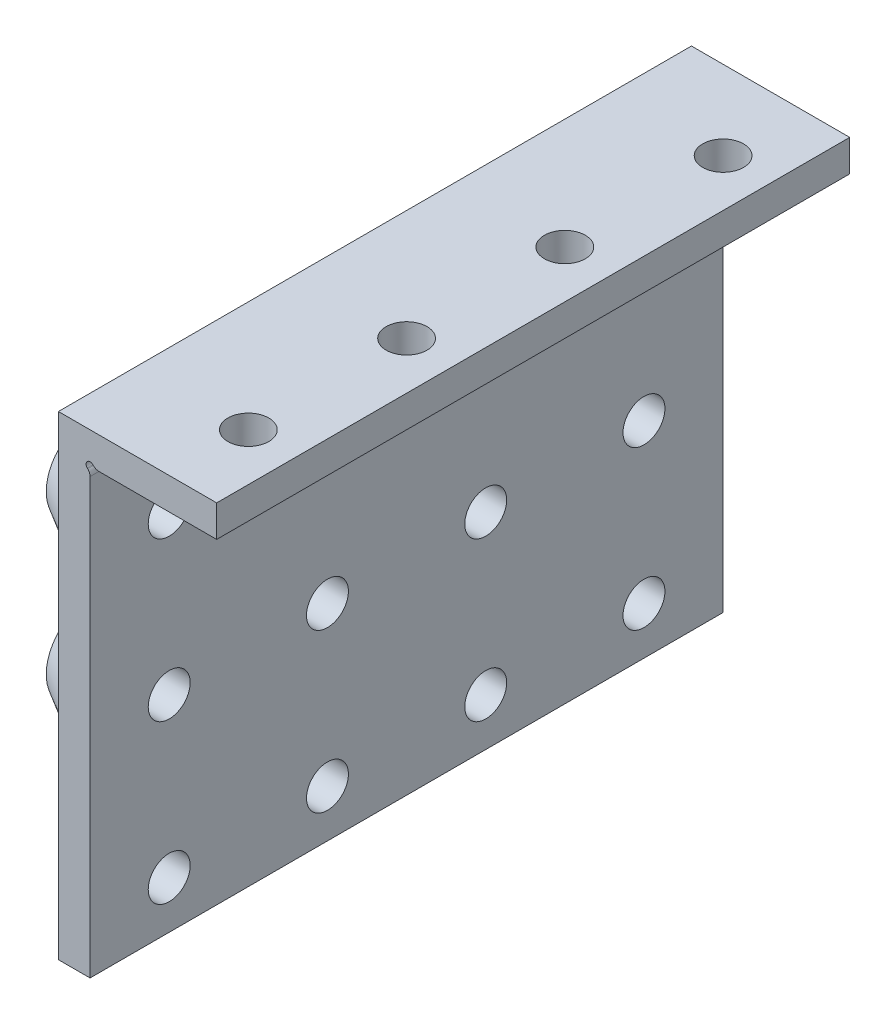
from build123d import *

# Parameters (mm, degrees)
BOSS_EXTRUDE1_DEPTH            = 80
SKETCH2_R                      = 9
BOSS_EXTRUDE2_DEPTH            = 6
BOSS_EXTRUDE2_DRAFT            = -30
BOSS_EXTRUDE2_PROFILE_2_DEPTH  = 6
BOSS_EXTRUDE2_PROFILE_2_DRAFT  = -30
BOSS_EXTRUDE2_PROFILE_3_DEPTH  = 6
BOSS_EXTRUDE2_PROFILE_3_DRAFT  = -30
BOSS_EXTRUDE2_PROFILE_4_DEPTH  = 6
BOSS_EXTRUDE2_PROFILE_4_DRAFT  = -30
BOSS_EXTRUDE2_PROFILE_5_DEPTH  = 6
BOSS_EXTRUDE2_PROFILE_5_DRAFT  = -30
BOSS_EXTRUDE2_PROFILE_6_DEPTH  = 6
BOSS_EXTRUDE2_PROFILE_6_DRAFT  = -30
BOSS_EXTRUDE2_PROFILE_7_DEPTH  = 6
BOSS_EXTRUDE2_PROFILE_7_DRAFT  = -30
BOSS_EXTRUDE2_PROFILE_8_DEPTH  = 6
BOSS_EXTRUDE2_PROFILE_8_DRAFT  = -30
CUT_EXTRUDE1_REACH             = 103.98
SKETCH2_4_R                    = 2.65
CUT_EXTRUDE1_DIRECTION_2_REACH = 103.98
CUT_EXTRUDE2_REACH             = 103.054
SKETCH3_R                      = 2.584003328
CUT_EXTRUDE3_REACH             = 105.325


with BuildPart() as part:
    # Sketch1 → Boss-Extrude1 (new body)
    with BuildSketch(Plane.XY):
        Polygon((0, 0), (-20, 0), (-20, -60), (-16, -60), (-16, -4), (0, -4), align=None)
    extrude(amount=BOSS_EXTRUDE1_DEPTH)


with BuildPart() as boss_extrude2_tool:
    # Sketch2 → Boss-Extrude2 (with draft: the straight prism first)
    with BuildSketch(Plane(origin=(-20, 0, 0), x_dir=(0, 0, -1), z_dir=(1, 0, 0))):
        with Locations((-10, -14)):
            Circle(SKETCH2_R)
    extrude(amount=-BOSS_EXTRUDE2_DEPTH)
    # Boss-Extrude2: the draft: its side faces are tilted about the plane it starts from
    boss_extrude2_sides = [boss_extrude2_tool.faces().sort_by_distance(p)[0] for p in [
        (-23, -14, 19),
    ]]
    draft(boss_extrude2_sides, Plane(origin=(-20, 0, 0), x_dir=(0, 0, -1), z_dir=(1, 0, 0)), BOSS_EXTRUDE2_DRAFT)


with BuildPart() as part_1:
    add(part.part)

    # Boss-Extrude2: add boss_extrude2_tool
    add(boss_extrude2_tool.part)


with BuildPart() as boss_extrude2_profile_2_tool:
    # Sketch2 → Boss-Extrude2 profile 2 (with draft: the straight prism first)
    with BuildSketch(Plane(origin=(-20, 0, 0), x_dir=(0, 0, -1), z_dir=(1, 0, 0))):
        with Locations((-30, -14)):
            Circle(SKETCH2_R)
    extrude(amount=-BOSS_EXTRUDE2_PROFILE_2_DEPTH)
    # Boss-Extrude2 profile 2: the draft: its side faces are tilted about the plane it starts from
    boss_extrude2_profile_2_sides = [boss_extrude2_profile_2_tool.faces().sort_by_distance(p)[0] for p in [
        (-23, -14, 39),
    ]]
    draft(boss_extrude2_profile_2_sides, Plane(origin=(-20, 0, 0), x_dir=(0, 0, -1), z_dir=(1, 0, 0)), BOSS_EXTRUDE2_PROFILE_2_DRAFT)


with BuildPart() as part_2:
    add(part_1.part)

    # Boss-Extrude2 profile 2: add boss_extrude2_profile_2_tool
    add(boss_extrude2_profile_2_tool.part)


with BuildPart() as boss_extrude2_profile_3_tool:
    # Sketch2 → Boss-Extrude2 profile 3 (with draft: the straight prism first)
    with BuildSketch(Plane(origin=(-20, 0, 0), x_dir=(0, 0, -1), z_dir=(1, 0, 0))):
        with Locations((-50, -14)):
            Circle(SKETCH2_R)
    extrude(amount=-BOSS_EXTRUDE2_PROFILE_3_DEPTH)
    # Boss-Extrude2 profile 3: the draft: its side faces are tilted about the plane it starts from
    boss_extrude2_profile_3_sides = [boss_extrude2_profile_3_tool.faces().sort_by_distance(p)[0] for p in [
        (-23, -14, 59),
    ]]
    draft(boss_extrude2_profile_3_sides, Plane(origin=(-20, 0, 0), x_dir=(0, 0, -1), z_dir=(1, 0, 0)), BOSS_EXTRUDE2_PROFILE_3_DRAFT)


with BuildPart() as part_3:
    add(part_2.part)

    # Boss-Extrude2 profile 3: add boss_extrude2_profile_3_tool
    add(boss_extrude2_profile_3_tool.part)


with BuildPart() as boss_extrude2_profile_4_tool:
    # Sketch2 → Boss-Extrude2 profile 4 (with draft: the straight prism first)
    with BuildSketch(Plane(origin=(-20, 0, 0), x_dir=(0, 0, -1), z_dir=(1, 0, 0))):
        with Locations((-70, -14)):
            Circle(SKETCH2_R)
    extrude(amount=-BOSS_EXTRUDE2_PROFILE_4_DEPTH)
    # Boss-Extrude2 profile 4: the draft: its side faces are tilted about the plane it starts from
    boss_extrude2_profile_4_sides = [boss_extrude2_profile_4_tool.faces().sort_by_distance(p)[0] for p in [
        (-23, -14, 79),
    ]]
    draft(boss_extrude2_profile_4_sides, Plane(origin=(-20, 0, 0), x_dir=(0, 0, -1), z_dir=(1, 0, 0)), BOSS_EXTRUDE2_PROFILE_4_DRAFT)


with BuildPart() as part_4:
    add(part_3.part)

    # Boss-Extrude2 profile 4: add boss_extrude2_profile_4_tool
    add(boss_extrude2_profile_4_tool.part)


with BuildPart() as boss_extrude2_profile_5_tool:
    # Sketch2 → Boss-Extrude2 profile 5 (with draft: the straight prism first)
    with BuildSketch(Plane(origin=(-20, 0, 0), x_dir=(0, 0, -1), z_dir=(1, 0, 0))):
        with Locations((-10, -34)):
            Circle(SKETCH2_R)
    extrude(amount=-BOSS_EXTRUDE2_PROFILE_5_DEPTH)
    # Boss-Extrude2 profile 5: the draft: its side faces are tilted about the plane it starts from
    boss_extrude2_profile_5_sides = [boss_extrude2_profile_5_tool.faces().sort_by_distance(p)[0] for p in [
        (-23, -34, 19),
    ]]
    draft(boss_extrude2_profile_5_sides, Plane(origin=(-20, 0, 0), x_dir=(0, 0, -1), z_dir=(1, 0, 0)), BOSS_EXTRUDE2_PROFILE_5_DRAFT)


with BuildPart() as part_5:
    add(part_4.part)

    # Boss-Extrude2 profile 5: add boss_extrude2_profile_5_tool
    add(boss_extrude2_profile_5_tool.part)


with BuildPart() as boss_extrude2_profile_6_tool:
    # Sketch2 → Boss-Extrude2 profile 6 (with draft: the straight prism first)
    with BuildSketch(Plane(origin=(-20, 0, 0), x_dir=(0, 0, -1), z_dir=(1, 0, 0))):
        with Locations((-30, -34)):
            Circle(SKETCH2_R)
    extrude(amount=-BOSS_EXTRUDE2_PROFILE_6_DEPTH)
    # Boss-Extrude2 profile 6: the draft: its side faces are tilted about the plane it starts from
    boss_extrude2_profile_6_sides = [boss_extrude2_profile_6_tool.faces().sort_by_distance(p)[0] for p in [
        (-23, -34, 39),
    ]]
    draft(boss_extrude2_profile_6_sides, Plane(origin=(-20, 0, 0), x_dir=(0, 0, -1), z_dir=(1, 0, 0)), BOSS_EXTRUDE2_PROFILE_6_DRAFT)


with BuildPart() as part_6:
    add(part_5.part)

    # Boss-Extrude2 profile 6: add boss_extrude2_profile_6_tool
    add(boss_extrude2_profile_6_tool.part)


with BuildPart() as boss_extrude2_profile_7_tool:
    # Sketch2 → Boss-Extrude2 profile 7 (with draft: the straight prism first)
    with BuildSketch(Plane(origin=(-20, 0, 0), x_dir=(0, 0, -1), z_dir=(1, 0, 0))):
        with Locations((-50, -34)):
            Circle(SKETCH2_R)
    extrude(amount=-BOSS_EXTRUDE2_PROFILE_7_DEPTH)
    # Boss-Extrude2 profile 7: the draft: its side faces are tilted about the plane it starts from
    boss_extrude2_profile_7_sides = [boss_extrude2_profile_7_tool.faces().sort_by_distance(p)[0] for p in [
        (-23, -34, 59),
    ]]
    draft(boss_extrude2_profile_7_sides, Plane(origin=(-20, 0, 0), x_dir=(0, 0, -1), z_dir=(1, 0, 0)), BOSS_EXTRUDE2_PROFILE_7_DRAFT)


with BuildPart() as part_7:
    add(part_6.part)

    # Boss-Extrude2 profile 7: add boss_extrude2_profile_7_tool
    add(boss_extrude2_profile_7_tool.part)


with BuildPart() as boss_extrude2_profile_8_tool:
    # Sketch2 → Boss-Extrude2 profile 8 (with draft: the straight prism first)
    with BuildSketch(Plane(origin=(-20, 0, 0), x_dir=(0, 0, -1), z_dir=(1, 0, 0))):
        with Locations((-70, -34)):
            Circle(SKETCH2_R)
    extrude(amount=-BOSS_EXTRUDE2_PROFILE_8_DEPTH)
    # Boss-Extrude2 profile 8: the draft: its side faces are tilted about the plane it starts from
    boss_extrude2_profile_8_sides = [boss_extrude2_profile_8_tool.faces().sort_by_distance(p)[0] for p in [
        (-23, -34, 79),
    ]]
    draft(boss_extrude2_profile_8_sides, Plane(origin=(-20, 0, 0), x_dir=(0, 0, -1), z_dir=(1, 0, 0)), BOSS_EXTRUDE2_PROFILE_8_DRAFT)


with BuildPart() as part_8:
    add(part_7.part)

    # Boss-Extrude2 profile 8: add boss_extrude2_profile_8_tool
    add(boss_extrude2_profile_8_tool.part)

    # Cut-Extrude1: up to this face of the body (flat: up to its plane)
    cut_extrude1_end = Plane(part_8.part.faces().sort_by_distance((-26, -14, 10))[0])
    # Sketch2_4 → Cut-Extrude1 (cut, up to the picked face)
    with BuildSketch(Plane(origin=(-20, 0, 0), x_dir=(0, 0, -1), z_dir=(1, 0, 0)), mode=Mode.PRIVATE) as cut_extrude1_sk1:
        with Locations((-10, -14)):
            Circle(SKETCH2_4_R)
    cut_extrude1_tool1 = split(extrude(cut_extrude1_sk1.sketch, amount=-CUT_EXTRUDE1_REACH, mode=Mode.PRIVATE), bisect_by=cut_extrude1_end, keep=Keep.BOTH, mode=Mode.PRIVATE)
    # Sketch2_4 → Cut-Extrude1 (cut, up to the picked face)
    with BuildSketch(Plane(origin=(-20, 0, 0), x_dir=(0, 0, -1), z_dir=(1, 0, 0)), mode=Mode.PRIVATE) as cut_extrude1_sk2:
        with Locations((-30, -14)):
            Circle(SKETCH2_4_R)
    cut_extrude1_tool2 = split(extrude(cut_extrude1_sk2.sketch, amount=-CUT_EXTRUDE1_REACH, mode=Mode.PRIVATE), bisect_by=cut_extrude1_end, keep=Keep.BOTH, mode=Mode.PRIVATE)
    # Sketch2_4 → Cut-Extrude1 (cut, up to the picked face)
    with BuildSketch(Plane(origin=(-20, 0, 0), x_dir=(0, 0, -1), z_dir=(1, 0, 0)), mode=Mode.PRIVATE) as cut_extrude1_sk3:
        with Locations((-50, -14)):
            Circle(SKETCH2_4_R)
    cut_extrude1_tool3 = split(extrude(cut_extrude1_sk3.sketch, amount=-CUT_EXTRUDE1_REACH, mode=Mode.PRIVATE), bisect_by=cut_extrude1_end, keep=Keep.BOTH, mode=Mode.PRIVATE)
    # Sketch2_4 → Cut-Extrude1 (cut, up to the picked face)
    with BuildSketch(Plane(origin=(-20, 0, 0), x_dir=(0, 0, -1), z_dir=(1, 0, 0)), mode=Mode.PRIVATE) as cut_extrude1_sk4:
        with Locations((-70, -14)):
            Circle(SKETCH2_4_R)
    cut_extrude1_tool4 = split(extrude(cut_extrude1_sk4.sketch, amount=-CUT_EXTRUDE1_REACH, mode=Mode.PRIVATE), bisect_by=cut_extrude1_end, keep=Keep.BOTH, mode=Mode.PRIVATE)
    # Sketch2_4 → Cut-Extrude1 (cut, up to the picked face)
    with BuildSketch(Plane(origin=(-20, 0, 0), x_dir=(0, 0, -1), z_dir=(1, 0, 0)), mode=Mode.PRIVATE) as cut_extrude1_sk5:
        with Locations((-10, -34)):
            Circle(SKETCH2_4_R)
    cut_extrude1_tool5 = split(extrude(cut_extrude1_sk5.sketch, amount=-CUT_EXTRUDE1_REACH, mode=Mode.PRIVATE), bisect_by=cut_extrude1_end, keep=Keep.BOTH, mode=Mode.PRIVATE)
    # Sketch2_4 → Cut-Extrude1 (cut, up to the picked face)
    with BuildSketch(Plane(origin=(-20, 0, 0), x_dir=(0, 0, -1), z_dir=(1, 0, 0)), mode=Mode.PRIVATE) as cut_extrude1_sk6:
        with Locations((-30, -34)):
            Circle(SKETCH2_4_R)
    cut_extrude1_tool6 = split(extrude(cut_extrude1_sk6.sketch, amount=-CUT_EXTRUDE1_REACH, mode=Mode.PRIVATE), bisect_by=cut_extrude1_end, keep=Keep.BOTH, mode=Mode.PRIVATE)
    # Sketch2_4 → Cut-Extrude1 (cut, up to the picked face)
    with BuildSketch(Plane(origin=(-20, 0, 0), x_dir=(0, 0, -1), z_dir=(1, 0, 0)), mode=Mode.PRIVATE) as cut_extrude1_sk7:
        with Locations((-50, -34)):
            Circle(SKETCH2_4_R)
    cut_extrude1_tool7 = split(extrude(cut_extrude1_sk7.sketch, amount=-CUT_EXTRUDE1_REACH, mode=Mode.PRIVATE), bisect_by=cut_extrude1_end, keep=Keep.BOTH, mode=Mode.PRIVATE)
    # Sketch2_4 → Cut-Extrude1 (cut, up to the picked face)
    with BuildSketch(Plane(origin=(-20, 0, 0), x_dir=(0, 0, -1), z_dir=(1, 0, 0)), mode=Mode.PRIVATE) as cut_extrude1_sk8:
        with Locations((-70, -34)):
            Circle(SKETCH2_4_R)
    cut_extrude1_tool8 = split(extrude(cut_extrude1_sk8.sketch, amount=-CUT_EXTRUDE1_REACH, mode=Mode.PRIVATE), bisect_by=cut_extrude1_end, keep=Keep.BOTH, mode=Mode.PRIVATE)
    # Sketch2_4 → Cut-Extrude1 (cut, up to the picked face)
    with BuildSketch(Plane(origin=(-20, 0, 0), x_dir=(0, 0, -1), z_dir=(1, 0, 0)), mode=Mode.PRIVATE) as cut_extrude1_sk9:
        with Locations((-70, -54)):
            Circle(SKETCH2_4_R)
    cut_extrude1_tool9 = split(extrude(cut_extrude1_sk9.sketch, amount=-CUT_EXTRUDE1_REACH, mode=Mode.PRIVATE), bisect_by=cut_extrude1_end, keep=Keep.BOTH, mode=Mode.PRIVATE)
    # Sketch2_4 → Cut-Extrude1 (cut, up to the picked face)
    with BuildSketch(Plane(origin=(-20, 0, 0), x_dir=(0, 0, -1), z_dir=(1, 0, 0)), mode=Mode.PRIVATE) as cut_extrude1_sk10:
        with Locations((-50, -54)):
            Circle(SKETCH2_4_R)
    cut_extrude1_tool10 = split(extrude(cut_extrude1_sk10.sketch, amount=-CUT_EXTRUDE1_REACH, mode=Mode.PRIVATE), bisect_by=cut_extrude1_end, keep=Keep.BOTH, mode=Mode.PRIVATE)
    # Sketch2_4 → Cut-Extrude1 (cut, up to the picked face)
    with BuildSketch(Plane(origin=(-20, 0, 0), x_dir=(0, 0, -1), z_dir=(1, 0, 0)), mode=Mode.PRIVATE) as cut_extrude1_sk11:
        with Locations((-30, -54)):
            Circle(SKETCH2_4_R)
    cut_extrude1_tool11 = split(extrude(cut_extrude1_sk11.sketch, amount=-CUT_EXTRUDE1_REACH, mode=Mode.PRIVATE), bisect_by=cut_extrude1_end, keep=Keep.BOTH, mode=Mode.PRIVATE)
    # Sketch2_4 → Cut-Extrude1 (cut, up to the picked face)
    with BuildSketch(Plane(origin=(-20, 0, 0), x_dir=(0, 0, -1), z_dir=(1, 0, 0)), mode=Mode.PRIVATE) as cut_extrude1_sk12:
        with Locations((-10, -54)):
            Circle(SKETCH2_4_R)
    cut_extrude1_tool12 = split(extrude(cut_extrude1_sk12.sketch, amount=-CUT_EXTRUDE1_REACH, mode=Mode.PRIVATE), bisect_by=cut_extrude1_end, keep=Keep.BOTH, mode=Mode.PRIVATE)
    add(cut_extrude1_tool1.solids().sort_by(Axis((-20, -14, 10), (-1, 0, 0)))[0], mode=Mode.SUBTRACT)
    add(cut_extrude1_tool2.solids().sort_by(Axis((-20, -14, 30), (-1, 0, 0)))[0], mode=Mode.SUBTRACT)
    add(cut_extrude1_tool3.solids().sort_by(Axis((-20, -14, 50), (-1, 0, 0)))[0], mode=Mode.SUBTRACT)
    add(cut_extrude1_tool4.solids().sort_by(Axis((-20, -14, 70), (-1, 0, 0)))[0], mode=Mode.SUBTRACT)
    add(cut_extrude1_tool5.solids().sort_by(Axis((-20, -34, 10), (-1, 0, 0)))[0], mode=Mode.SUBTRACT)
    add(cut_extrude1_tool6.solids().sort_by(Axis((-20, -34, 30), (-1, 0, 0)))[0], mode=Mode.SUBTRACT)
    add(cut_extrude1_tool7.solids().sort_by(Axis((-20, -34, 50), (-1, 0, 0)))[0], mode=Mode.SUBTRACT)
    add(cut_extrude1_tool8.solids().sort_by(Axis((-20, -34, 70), (-1, 0, 0)))[0], mode=Mode.SUBTRACT)
    add(cut_extrude1_tool9.solids().sort_by(Axis((-20, -54, 70), (-1, 0, 0)))[0], mode=Mode.SUBTRACT)
    add(cut_extrude1_tool10.solids().sort_by(Axis((-20, -54, 50), (-1, 0, 0)))[0], mode=Mode.SUBTRACT)
    add(cut_extrude1_tool11.solids().sort_by(Axis((-20, -54, 30), (-1, 0, 0)))[0], mode=Mode.SUBTRACT)
    add(cut_extrude1_tool12.solids().sort_by(Axis((-20, -54, 10), (-1, 0, 0)))[0], mode=Mode.SUBTRACT)

    # Cut-Extrude1 direction 2: up to this face of the body (flat: up to its plane)
    cut_extrude1_direction_2_end = Plane(part_8.part.faces().sort_by_distance((-16, -32, 40))[0])
    # Sketch2_4 → Cut-Extrude1 direction 2 (cut, up to the picked face)
    with BuildSketch(Plane(origin=(-20, 0, 0), x_dir=(0, 0, -1), z_dir=(1, 0, 0)), mode=Mode.PRIVATE) as cut_extrude1_direction_2_sk1:
        with Locations((-10, -14)):
            Circle(SKETCH2_4_R)
    cut_extrude1_direction_2_tool1 = split(extrude(cut_extrude1_direction_2_sk1.sketch, amount=CUT_EXTRUDE1_DIRECTION_2_REACH, mode=Mode.PRIVATE), bisect_by=cut_extrude1_direction_2_end, keep=Keep.BOTH, mode=Mode.PRIVATE)
    # Sketch2_4 → Cut-Extrude1 direction 2 (cut, up to the picked face)
    with BuildSketch(Plane(origin=(-20, 0, 0), x_dir=(0, 0, -1), z_dir=(1, 0, 0)), mode=Mode.PRIVATE) as cut_extrude1_direction_2_sk2:
        with Locations((-30, -14)):
            Circle(SKETCH2_4_R)
    cut_extrude1_direction_2_tool2 = split(extrude(cut_extrude1_direction_2_sk2.sketch, amount=CUT_EXTRUDE1_DIRECTION_2_REACH, mode=Mode.PRIVATE), bisect_by=cut_extrude1_direction_2_end, keep=Keep.BOTH, mode=Mode.PRIVATE)
    # Sketch2_4 → Cut-Extrude1 direction 2 (cut, up to the picked face)
    with BuildSketch(Plane(origin=(-20, 0, 0), x_dir=(0, 0, -1), z_dir=(1, 0, 0)), mode=Mode.PRIVATE) as cut_extrude1_direction_2_sk3:
        with Locations((-50, -14)):
            Circle(SKETCH2_4_R)
    cut_extrude1_direction_2_tool3 = split(extrude(cut_extrude1_direction_2_sk3.sketch, amount=CUT_EXTRUDE1_DIRECTION_2_REACH, mode=Mode.PRIVATE), bisect_by=cut_extrude1_direction_2_end, keep=Keep.BOTH, mode=Mode.PRIVATE)
    # Sketch2_4 → Cut-Extrude1 direction 2 (cut, up to the picked face)
    with BuildSketch(Plane(origin=(-20, 0, 0), x_dir=(0, 0, -1), z_dir=(1, 0, 0)), mode=Mode.PRIVATE) as cut_extrude1_direction_2_sk4:
        with Locations((-70, -14)):
            Circle(SKETCH2_4_R)
    cut_extrude1_direction_2_tool4 = split(extrude(cut_extrude1_direction_2_sk4.sketch, amount=CUT_EXTRUDE1_DIRECTION_2_REACH, mode=Mode.PRIVATE), bisect_by=cut_extrude1_direction_2_end, keep=Keep.BOTH, mode=Mode.PRIVATE)
    # Sketch2_4 → Cut-Extrude1 direction 2 (cut, up to the picked face)
    with BuildSketch(Plane(origin=(-20, 0, 0), x_dir=(0, 0, -1), z_dir=(1, 0, 0)), mode=Mode.PRIVATE) as cut_extrude1_direction_2_sk5:
        with Locations((-10, -34)):
            Circle(SKETCH2_4_R)
    cut_extrude1_direction_2_tool5 = split(extrude(cut_extrude1_direction_2_sk5.sketch, amount=CUT_EXTRUDE1_DIRECTION_2_REACH, mode=Mode.PRIVATE), bisect_by=cut_extrude1_direction_2_end, keep=Keep.BOTH, mode=Mode.PRIVATE)
    # Sketch2_4 → Cut-Extrude1 direction 2 (cut, up to the picked face)
    with BuildSketch(Plane(origin=(-20, 0, 0), x_dir=(0, 0, -1), z_dir=(1, 0, 0)), mode=Mode.PRIVATE) as cut_extrude1_direction_2_sk6:
        with Locations((-30, -34)):
            Circle(SKETCH2_4_R)
    cut_extrude1_direction_2_tool6 = split(extrude(cut_extrude1_direction_2_sk6.sketch, amount=CUT_EXTRUDE1_DIRECTION_2_REACH, mode=Mode.PRIVATE), bisect_by=cut_extrude1_direction_2_end, keep=Keep.BOTH, mode=Mode.PRIVATE)
    # Sketch2_4 → Cut-Extrude1 direction 2 (cut, up to the picked face)
    with BuildSketch(Plane(origin=(-20, 0, 0), x_dir=(0, 0, -1), z_dir=(1, 0, 0)), mode=Mode.PRIVATE) as cut_extrude1_direction_2_sk7:
        with Locations((-50, -34)):
            Circle(SKETCH2_4_R)
    cut_extrude1_direction_2_tool7 = split(extrude(cut_extrude1_direction_2_sk7.sketch, amount=CUT_EXTRUDE1_DIRECTION_2_REACH, mode=Mode.PRIVATE), bisect_by=cut_extrude1_direction_2_end, keep=Keep.BOTH, mode=Mode.PRIVATE)
    # Sketch2_4 → Cut-Extrude1 direction 2 (cut, up to the picked face)
    with BuildSketch(Plane(origin=(-20, 0, 0), x_dir=(0, 0, -1), z_dir=(1, 0, 0)), mode=Mode.PRIVATE) as cut_extrude1_direction_2_sk8:
        with Locations((-70, -34)):
            Circle(SKETCH2_4_R)
    cut_extrude1_direction_2_tool8 = split(extrude(cut_extrude1_direction_2_sk8.sketch, amount=CUT_EXTRUDE1_DIRECTION_2_REACH, mode=Mode.PRIVATE), bisect_by=cut_extrude1_direction_2_end, keep=Keep.BOTH, mode=Mode.PRIVATE)
    # Sketch2_4 → Cut-Extrude1 direction 2 (cut, up to the picked face)
    with BuildSketch(Plane(origin=(-20, 0, 0), x_dir=(0, 0, -1), z_dir=(1, 0, 0)), mode=Mode.PRIVATE) as cut_extrude1_direction_2_sk9:
        with Locations((-70, -54)):
            Circle(SKETCH2_4_R)
    cut_extrude1_direction_2_tool9 = split(extrude(cut_extrude1_direction_2_sk9.sketch, amount=CUT_EXTRUDE1_DIRECTION_2_REACH, mode=Mode.PRIVATE), bisect_by=cut_extrude1_direction_2_end, keep=Keep.BOTH, mode=Mode.PRIVATE)
    # Sketch2_4 → Cut-Extrude1 direction 2 (cut, up to the picked face)
    with BuildSketch(Plane(origin=(-20, 0, 0), x_dir=(0, 0, -1), z_dir=(1, 0, 0)), mode=Mode.PRIVATE) as cut_extrude1_direction_2_sk10:
        with Locations((-50, -54)):
            Circle(SKETCH2_4_R)
    cut_extrude1_direction_2_tool10 = split(extrude(cut_extrude1_direction_2_sk10.sketch, amount=CUT_EXTRUDE1_DIRECTION_2_REACH, mode=Mode.PRIVATE), bisect_by=cut_extrude1_direction_2_end, keep=Keep.BOTH, mode=Mode.PRIVATE)
    # Sketch2_4 → Cut-Extrude1 direction 2 (cut, up to the picked face)
    with BuildSketch(Plane(origin=(-20, 0, 0), x_dir=(0, 0, -1), z_dir=(1, 0, 0)), mode=Mode.PRIVATE) as cut_extrude1_direction_2_sk11:
        with Locations((-30, -54)):
            Circle(SKETCH2_4_R)
    cut_extrude1_direction_2_tool11 = split(extrude(cut_extrude1_direction_2_sk11.sketch, amount=CUT_EXTRUDE1_DIRECTION_2_REACH, mode=Mode.PRIVATE), bisect_by=cut_extrude1_direction_2_end, keep=Keep.BOTH, mode=Mode.PRIVATE)
    # Sketch2_4 → Cut-Extrude1 direction 2 (cut, up to the picked face)
    with BuildSketch(Plane(origin=(-20, 0, 0), x_dir=(0, 0, -1), z_dir=(1, 0, 0)), mode=Mode.PRIVATE) as cut_extrude1_direction_2_sk12:
        with Locations((-10, -54)):
            Circle(SKETCH2_4_R)
    cut_extrude1_direction_2_tool12 = split(extrude(cut_extrude1_direction_2_sk12.sketch, amount=CUT_EXTRUDE1_DIRECTION_2_REACH, mode=Mode.PRIVATE), bisect_by=cut_extrude1_direction_2_end, keep=Keep.BOTH, mode=Mode.PRIVATE)
    add(cut_extrude1_direction_2_tool1.solids().sort_by(Axis((-20, -14, 10), (1, 0, 0)))[0], mode=Mode.SUBTRACT)
    add(cut_extrude1_direction_2_tool2.solids().sort_by(Axis((-20, -14, 30), (1, 0, 0)))[0], mode=Mode.SUBTRACT)
    add(cut_extrude1_direction_2_tool3.solids().sort_by(Axis((-20, -14, 50), (1, 0, 0)))[0], mode=Mode.SUBTRACT)
    add(cut_extrude1_direction_2_tool4.solids().sort_by(Axis((-20, -14, 70), (1, 0, 0)))[0], mode=Mode.SUBTRACT)
    add(cut_extrude1_direction_2_tool5.solids().sort_by(Axis((-20, -34, 10), (1, 0, 0)))[0], mode=Mode.SUBTRACT)
    add(cut_extrude1_direction_2_tool6.solids().sort_by(Axis((-20, -34, 30), (1, 0, 0)))[0], mode=Mode.SUBTRACT)
    add(cut_extrude1_direction_2_tool7.solids().sort_by(Axis((-20, -34, 50), (1, 0, 0)))[0], mode=Mode.SUBTRACT)
    add(cut_extrude1_direction_2_tool8.solids().sort_by(Axis((-20, -34, 70), (1, 0, 0)))[0], mode=Mode.SUBTRACT)
    add(cut_extrude1_direction_2_tool9.solids().sort_by(Axis((-20, -54, 70), (1, 0, 0)))[0], mode=Mode.SUBTRACT)
    add(cut_extrude1_direction_2_tool10.solids().sort_by(Axis((-20, -54, 50), (1, 0, 0)))[0], mode=Mode.SUBTRACT)
    add(cut_extrude1_direction_2_tool11.solids().sort_by(Axis((-20, -54, 30), (1, 0, 0)))[0], mode=Mode.SUBTRACT)
    add(cut_extrude1_direction_2_tool12.solids().sort_by(Axis((-20, -54, 10), (1, 0, 0)))[0], mode=Mode.SUBTRACT)

    # Sketch3 → Cut-Extrude2 (cut, up to next)
    with BuildSketch(Plane.XZ.offset(4), mode=Mode.PRIVATE) as cut_extrude2_sk1:
        with Locations((-6, 10)):
            Circle(SKETCH3_R)
    cut_extrude2_tool1 = extrude(cut_extrude2_sk1.sketch, amount=-CUT_EXTRUDE2_REACH, mode=Mode.PRIVATE) & part_8.part
    # Sketch3 → Cut-Extrude2 (cut, up to next)
    with BuildSketch(Plane.XZ.offset(4), mode=Mode.PRIVATE) as cut_extrude2_sk2:
        with Locations((-6, 30)):
            Circle(SKETCH3_R)
    cut_extrude2_tool2 = extrude(cut_extrude2_sk2.sketch, amount=-CUT_EXTRUDE2_REACH, mode=Mode.PRIVATE) & part_8.part
    # Sketch3 → Cut-Extrude2 (cut, up to next)
    with BuildSketch(Plane.XZ.offset(4), mode=Mode.PRIVATE) as cut_extrude2_sk3:
        with Locations((-6, 50)):
            Circle(SKETCH3_R)
    cut_extrude2_tool3 = extrude(cut_extrude2_sk3.sketch, amount=-CUT_EXTRUDE2_REACH, mode=Mode.PRIVATE) & part_8.part
    # Sketch3 → Cut-Extrude2 (cut, up to next)
    with BuildSketch(Plane.XZ.offset(4), mode=Mode.PRIVATE) as cut_extrude2_sk4:
        with Locations((-6, 70)):
            Circle(SKETCH3_R)
    cut_extrude2_tool4 = extrude(cut_extrude2_sk4.sketch, amount=-CUT_EXTRUDE2_REACH, mode=Mode.PRIVATE) & part_8.part
    add(cut_extrude2_tool1.solids().sort_by_distance((-6, -4, 10))[0], mode=Mode.SUBTRACT)
    add(cut_extrude2_tool2.solids().sort_by_distance((-6, -4, 30))[0], mode=Mode.SUBTRACT)
    add(cut_extrude2_tool3.solids().sort_by_distance((-6, -4, 50))[0], mode=Mode.SUBTRACT)
    add(cut_extrude2_tool4.solids().sort_by_distance((-6, -4, 70))[0], mode=Mode.SUBTRACT)

    # Sketch4 → Cut-Extrude3 (cut, up to next)
    with BuildSketch(Plane(origin=(0, 0, 0), x_dir=(-1, 0, 0), z_dir=(0, 0, -1)), mode=Mode.PRIVATE) as cut_extrude3_sk1:
        with BuildLine():
            Line((15.646446609, -3.646446609), (15.585786438, -3.707106781))
            ThreePointArc((15.585786438, -3.707106781), (15.261363089, -3.923879533), (14.878679656, -4))
            Line((14.878679656, -4), (16, -5.121320344))
            ThreePointArc((16, -5.121320344), (16.076120467, -4.738636911), (16.292893219, -4.414213562))
            Line((16.292893219, -4.414213562), (16.353553391, -4.353553391))
            ThreePointArc((16.353553391, -4.353553391), (16.353553391, -3.646446609), (15.646446609, -3.646446609))
        make_face()
    cut_extrude3_tool1 = extrude(cut_extrude3_sk1.sketch, amount=-CUT_EXTRUDE3_REACH, mode=Mode.PRIVATE) & part_8.part
    add(cut_extrude3_tool1.solids().sort_by_distance((-15.832643, -4.167357, 0))[0], mode=Mode.SUBTRACT)


solid = part_8.part
